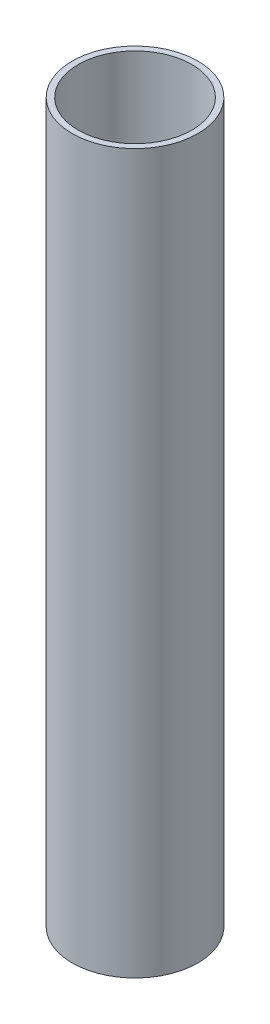
from build123d import *

# Parameters (mm, degrees)
SKETCH1_R           = 21
SKETCH1_R_2         = 19
EXTRUDE_THIN1_DEPTH = 240


with BuildPart() as part:
    # Sketch1 → Extrude-Thin1 (new body)
    with BuildSketch(Plane(origin=(0, 0, 0), x_dir=(1, 0, 0), z_dir=(0, 1, 0))):
        Circle(SKETCH1_R)
        Circle(SKETCH1_R_2, mode=Mode.SUBTRACT)
    extrude(amount=EXTRUDE_THIN1_DEPTH)


solid = part.part
